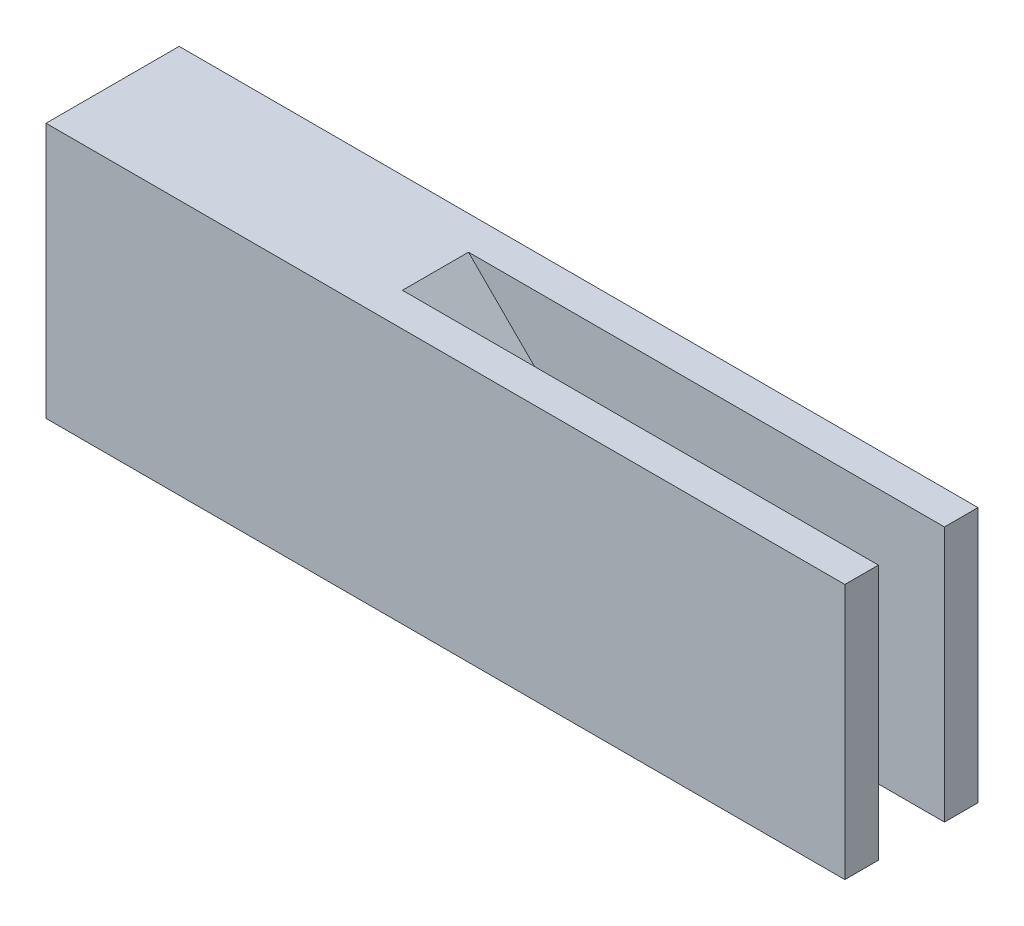
from build123d import *

# Parameters (mm, degrees)
SKETCH1_W           = 6.35
SKETCH1_H           = 12.192
BOSS_EXTRUDE1_DEPTH = 25.4
SKETCH2_W           = 1.6002
SKETCH2_H           = 12.192
BOSS_EXTRUDE2_DEPTH = 12.7
CHAMFER1_SIZE       = 10


with BuildPart() as part:
    # Sketch1 → Boss-Extrude1 (new body)
    with BuildSketch(Plane(origin=(0, 0, 0), x_dir=(0, 0, -1), z_dir=(1, 0, 0))):
        with Locations((3.175, 6.096)):
            Rectangle(SKETCH1_W, SKETCH1_H)
    extrude(amount=BOSS_EXTRUDE1_DEPTH)

    # Sketch2 → Boss-Extrude2 (add)
    with BuildSketch(Plane(origin=(25.4, 0, 0), x_dir=(0, 0, -1), z_dir=(1, 0, 0))):
        with Locations((0.8001, 6.096)):
            Rectangle(SKETCH2_W, SKETCH2_H)
        with Locations((5.5499, 6.096)):
            Rectangle(SKETCH2_W, SKETCH2_H)
    extrude(amount=BOSS_EXTRUDE2_DEPTH)

    # Chamfer1
    chamfer1_edges = [part.edges().sort_by_distance(p)[0] for p in [
        (25.4, 12.192, -3.175),
    ]]
    chamfer(chamfer1_edges, length=CHAMFER1_SIZE)


solid = part.part
